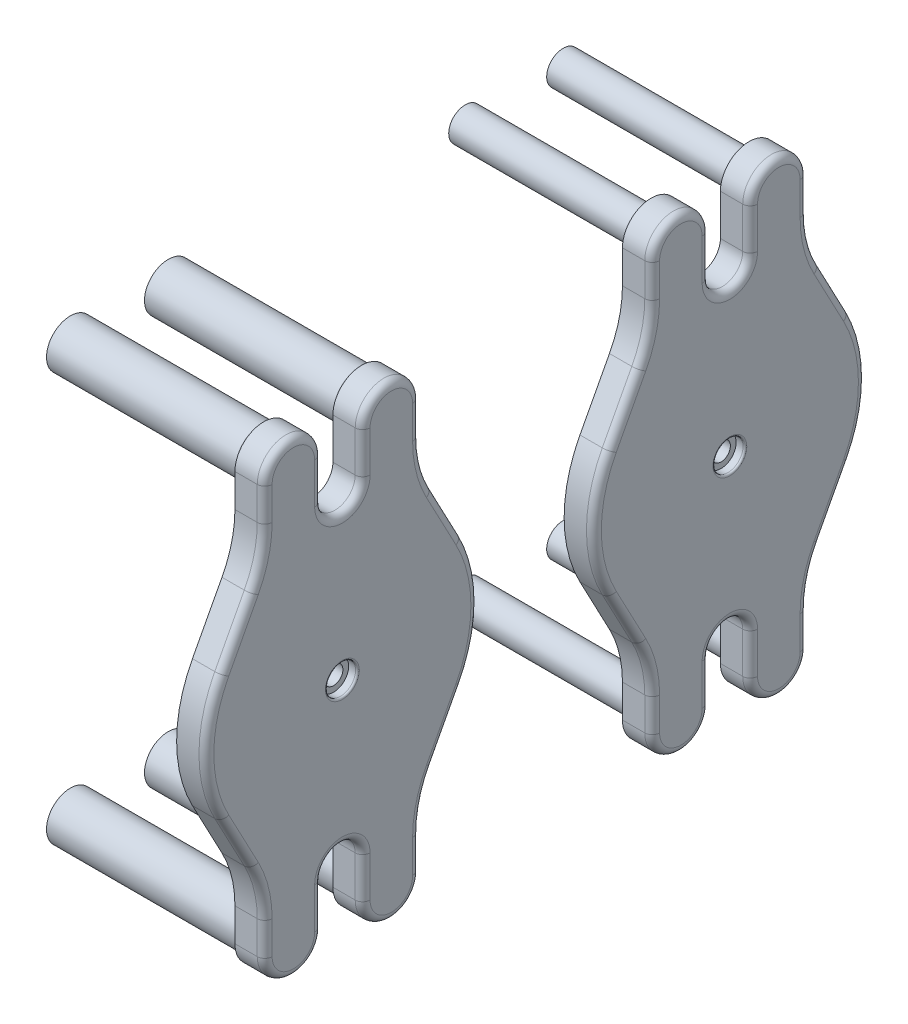
from build123d import *

# Parameters (mm, degrees)
SKETCH1_W           = 12
SKETCH1_H           = 18.25
SKETCH2_R           = 3.7145
CUT_EXTRUDE1_DEPTH  = 8.5725
SKETCH3_R           = 18.25
BOSS_EXTRUDE1_DEPTH = 8
SKETCH4_R           = 6.4
SKETCH4_R_2         = 4.75
BOSS_EXTRUDE2_DEPTH = 52
FILLET1_R           = 2
SKETCH6_R           = 13.15
CUT_EXTRUDE2_DEPTH  = 12
SKETCH12_R          = 4.05
CUT_EXTRUDE6_DEPTH  = 2.36
SKETCH12_6_R        = 2.5
CUT_EXTRUDE7_DEPTH  = 8
FILLET2_R           = 0.5
FILLET3_R           = 1
SKETCH13_R          = 7.4
SKETCH13_R_2        = 4.45
CUT_EXTRUDE8_DEPTH  = 52
BOSS_EXTRUDE4_START = -2
SKETCH13_3_R        = 4.45
BOSS_EXTRUDE4_DEPTH = 50
FILLET4_R           = 1


with BuildPart() as part:
    # Sketch1 → Revolve1 (revolve)
    with BuildSketch(Plane.XY):
        with Locations((14.255, 9.125)):
            Rectangle(SKETCH1_W, SKETCH1_H)
    revolve(axis=Axis((8.255, 0, 0), (1, 0, 0)))

    # Sketch2 → Cut-Extrude1 (cut)
    with BuildSketch(Plane.ZY.offset(-8.255)):
        Circle(SKETCH2_R)
    extrude(amount=-CUT_EXTRUDE1_DEPTH, mode=Mode.SUBTRACT)

    # Sketch6 → Cut-Extrude2 (cut)
    with BuildSketch(Plane.ZY.offset(-8.255)):
        Circle(SKETCH6_R)
    extrude(amount=-CUT_EXTRUDE2_DEPTH, mode=Mode.SUBTRACT)


with BuildPart() as body_2:
    # Sketch3 → Boss-Extrude1 (new body)
    with BuildSketch(Plane(origin=(20.255, 0, 0), x_dir=(0, 0, -1), z_dir=(1, 0, 0))):
        with BuildLine():
            Line((-24.382347836, 32.115154563), (-32.324530318, 17.115154563))
            ThreePointArc((-32.324530318, 17.115154563), (-36.576, 0), (-32.324530318, -17.115154563))
            Line((-32.324530318, -17.115154563), (-24.382347836, -32.115154563))
            ThreePointArc((-24.382347836, -32.115154563), (-21.780072988, -38.920854003), (-20.89525, -46.153175037))
            Line((-20.89525, -46.153175037), (-20.89525, -55))
            ThreePointArc((-20.89525, -55), (-13.175, -62.72025), (-5.45475, -55))
            Line((-5.45475, -55), (-5.45475, -44))
            ThreePointArc((-5.45475, -44), (0, -38.54525), (5.45475, -44))
            Line((5.45475, -44), (5.45475, -55))
            ThreePointArc((5.45475, -55), (13.175, -62.72025), (20.89525, -55))
            Line((20.89525, -55), (20.89525, -46.153175037))
            ThreePointArc((20.89525, -46.153175037), (21.780072988, -38.920854003), (24.382347836, -32.115154563))
            Line((24.382347836, -32.115154563), (32.324530318, -17.115154563))
            ThreePointArc((32.324530318, -17.115154563), (36.576, 0), (32.324530318, 17.115154563))
            Line((32.324530318, 17.115154563), (24.382347836, 32.115154563))
            ThreePointArc((24.382347836, 32.115154563), (21.780072988, 38.920854003), (20.89525, 46.153175037))
            Line((20.89525, 46.153175037), (20.89525, 55))
            ThreePointArc((20.89525, 55), (13.175, 62.72025), (5.45475, 55))
            Line((5.45475, 55), (5.45475, 44))
            ThreePointArc((5.45475, 44), (0, 38.54525), (-5.45475, 44))
            Line((-5.45475, 44), (-5.45475, 55))
            ThreePointArc((-5.45475, 55), (-13.175, 62.72025), (-20.89525, 55))
            Line((-20.89525, 55), (-20.89525, 46.153175037))
            ThreePointArc((-20.89525, 46.153175037), (-21.780072988, 38.920854003), (-24.382347836, 32.115154563))
        make_face()
        Circle(SKETCH3_R, mode=Mode.SUBTRACT)
        Circle(SKETCH3_R)
    extrude(amount=BOSS_EXTRUDE1_DEPTH)

    # Sketch4 → Boss-Extrude2 (add)
    with BuildSketch(Plane.ZY.offset(-20.255)):
        with Locations((-13.175, 55)):
            Circle(SKETCH4_R)
        with Locations((-13.175, 55)):
            Circle(SKETCH4_R_2, mode=Mode.SUBTRACT)
        with Locations((13.175, 55)):
            Circle(SKETCH4_R)
        with Locations((13.175, 55)):
            Circle(SKETCH4_R_2, mode=Mode.SUBTRACT)
        with Locations((13.175, -55)):
            Circle(SKETCH4_R)
        with Locations((13.175, -55)):
            Circle(SKETCH4_R_2, mode=Mode.SUBTRACT)
        with Locations((-13.175, -55)):
            Circle(SKETCH4_R)
        with Locations((-13.175, -55)):
            Circle(SKETCH4_R_2, mode=Mode.SUBTRACT)
    extrude(amount=BOSS_EXTRUDE2_DEPTH)

    # Fillet1
    fillet1_edges = [body_2.edges().sort_by_distance(p)[0] for p in [
        (28.255, 0, 36.576),
        (28.255, 38.54525, 0),
        (28.255, 49.5, 5.45475),
        (28.255, 62.72025, 13.175),
        (28.255, 50.576587519, 20.89525),
        (28.255, 38.920854003, 21.780072988),
        (28.255, -24.615154563, 28.353439077),
        (28.255, -38.920854003, 21.780072988),
        (28.255, -50.576587519, 20.89525),
        (28.255, -62.72025, 13.175),
        (28.255, -49.5, 5.45475),
        (28.255, -38.54525, 0),
        (28.255, -49.5, -5.45475),
        (28.255, 24.615154563, 28.353439077),
        (28.255, -62.72025, -13.175),
        (28.255, -50.576587519, -20.89525),
        (28.255, -38.920854003, -21.780072988),
        (28.255, -24.615154563, -28.353439077),
        (28.255, 0, -36.576),
        (28.255, 24.615154563, -28.353439077),
        (28.255, 38.920854003, -21.780072988),
        (28.255, 50.576587519, -20.89525),
        (28.255, 62.72025, -13.175),
        (28.255, 49.5, -5.45475),
    ]]
    fillet(fillet1_edges, radius=FILLET1_R)

    # Sketch12 → Cut-Extrude6 (cut)
    with BuildSketch(Plane(origin=(28.255, 0, 0), x_dir=(0, 0, -1), z_dir=(1, 0, 0))):
        Circle(SKETCH12_R)
    extrude(amount=-CUT_EXTRUDE6_DEPTH, mode=Mode.SUBTRACT)

    # Sketch12_6 → Cut-Extrude7 (cut)
    with BuildSketch(Plane(origin=(28.255, 0, 0), x_dir=(0, 0, -1), z_dir=(1, 0, 0))):
        Circle(SKETCH12_6_R)
    extrude(amount=-CUT_EXTRUDE7_DEPTH, mode=Mode.SUBTRACT)

    # Fillet2
    fillet2_edges = [body_2.edges().sort_by_distance(p)[0] for p in [
        (28.255, 0, 4.05),
    ]]
    fillet(fillet2_edges, radius=FILLET2_R)


with BuildPart() as part_1:
    add(part.part)

    # Combine1: union body 2
    add(body_2.part)

    # Fillet3
    fillet3_edges = [part_1.edges().sort_by_distance(p)[0] for p in [
        (20.255, -18.25, 0),
        (20.255, 55, -19.575),
        (20.255, 55, 6.775),
        (20.255, -55, 6.775),
        (20.255, -55, -19.575),
    ]]
    fillet(fillet3_edges, radius=FILLET3_R)


with BuildPart() as body_2_2:
    # Body-Move_Copy1: copy of part
    add(part_1.part.moved(Location((0, 0, -104.230204275))))

    # Sketch13 → Cut-Extrude8 (cut)
    with BuildSketch(Plane.ZY.offset(31.745)):
        with Locations((-117.405204275, 55)):
            Circle(SKETCH13_R)
        with Locations((-117.405204275, 55)):
            Circle(SKETCH13_R_2, mode=Mode.SUBTRACT)
        with Locations((-91.055204275, 55)):
            Circle(SKETCH13_R)
        with Locations((-91.055204275, 55)):
            Circle(SKETCH13_R_2, mode=Mode.SUBTRACT)
        with Locations((-117.405204275, -55)):
            Circle(SKETCH13_R)
        with Locations((-117.405204275, -55)):
            Circle(SKETCH13_R_2, mode=Mode.SUBTRACT)
        with Locations((-91.055204275, -55)):
            Circle(SKETCH13_R)
        with Locations((-91.055204275, -55)):
            Circle(SKETCH13_R_2, mode=Mode.SUBTRACT)
    extrude(amount=-CUT_EXTRUDE8_DEPTH, mode=Mode.SUBTRACT)

    # Sketch13_3 → Boss-Extrude4 (add)
    with BuildSketch(Plane.ZY.offset(31.745).offset(BOSS_EXTRUDE4_START)):
        with Locations((-91.055204275, 55)):
            Circle(SKETCH13_3_R)
        with Locations((-117.405204275, -55)):
            Circle(SKETCH13_3_R)
        with Locations((-91.055204275, -55)):
            Circle(SKETCH13_3_R)
        with Locations((-117.405204275, 55)):
            Circle(SKETCH13_3_R)
    extrude(amount=-BOSS_EXTRUDE4_DEPTH)

    # Fillet4
    fillet4_edges = [body_2_2.edges().sort_by_distance(p)[0] for p in [
        (20.255, 55, -95.505204275),
        (20.255, -55, -121.855204275),
        (20.255, -55, -95.505204275),
        (20.255, 55, -121.855204275),
    ]]
    fillet(fillet4_edges, radius=FILLET4_R)


solid = Compound([part_1.part, body_2_2.part])
